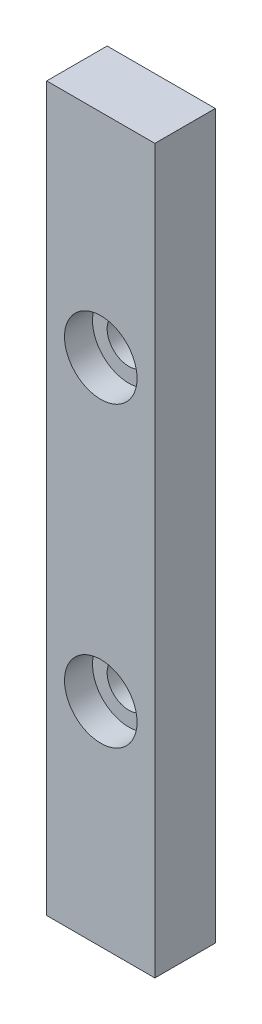
from build123d import *

# Parameters (mm, degrees)
SKETCH1_W                = 8.5
SKETCH1_H                = 56.8
BOSS_EXTRUDE1_DEPTH      = 4.75
M3_CLEARANCE_HOLE1_D     = 3.4
M3_CLEARANCE_HOLE1_DEPTH = 5
M3_CLEARANCE_HOLE1_TIP   = 1.021463052
SKETCH6_R                = 2.85
CUT_EXTRUDE1_DEPTH       = 2.2


with BuildPart() as part:
    # Sketch1 → Boss-Extrude1 (new body)
    with BuildSketch(Plane.XY):
        with Locations((4.25, -28.4)):
            Rectangle(SKETCH1_W, SKETCH1_H)
    extrude(amount=BOSS_EXTRUDE1_DEPTH)

    # M3 Clearance Hole1
    with Locations(Plane.XY.offset(4.75)):
        with Locations((4.25, -16.7), (4.25, -40.1)):
            Hole(M3_CLEARANCE_HOLE1_D / 2, depth=M3_CLEARANCE_HOLE1_DEPTH)
            with Locations((0, 0, -(M3_CLEARANCE_HOLE1_DEPTH + M3_CLEARANCE_HOLE1_TIP / 2))):  # 118° drill point
                Cone(0, M3_CLEARANCE_HOLE1_D / 2, M3_CLEARANCE_HOLE1_TIP, mode=Mode.SUBTRACT)

    # Sketch6 → Cut-Extrude1 (cut)
    with BuildSketch(Plane.XY.offset(4.75)):
        with Locations((4.25, -16.7)):
            Circle(SKETCH6_R)
        with Locations((4.25, -40.1)):
            Circle(SKETCH6_R)
    extrude(amount=-CUT_EXTRUDE1_DEPTH, mode=Mode.SUBTRACT)


solid = part.part
